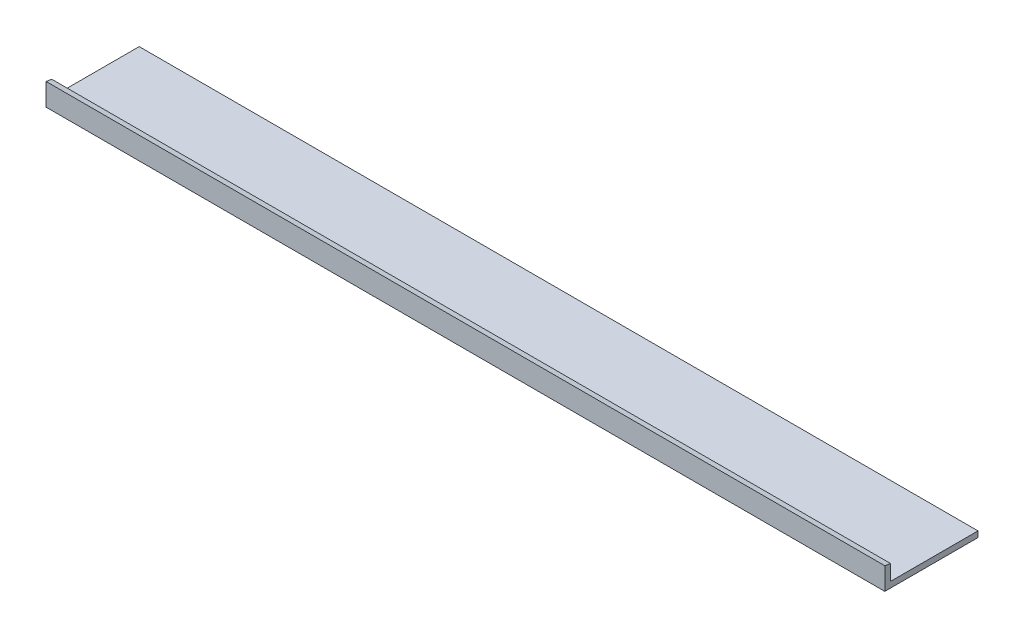
from build123d import *

# Parameters (mm, degrees)
SKETCH1_W           = 50.8
SKETCH1_H           = 12.13231
BOSS_EXTRUDE1_DEPTH = 457.2
CUT_EXTRUDE1_DEPTH  = 457.2


with BuildPart() as part:
    # Sketch1 → Boss-Extrude1 (new body)
    with BuildSketch(Plane(origin=(0, 0, 0), x_dir=(0, 0, -1), z_dir=(1, 0, 0))):
        with Locations((25.4, 6.066155)):
            Rectangle(SKETCH1_W, SKETCH1_H)
    extrude(amount=BOSS_EXTRUDE1_DEPTH)

    # Sketch2 → Cut-Extrude1 (cut)
    with BuildSketch(Plane.ZY):
        Polygon((-41.275, 12.13231), (-3.175, 12.13231), (0, 12.13231), (-3.175, 11.572471836), (-3.175, 3.175), (-41.275, 3.175), (-50.8, 3.175), (-50.8, 12.13231), align=None)
    extrude(amount=-CUT_EXTRUDE1_DEPTH, mode=Mode.SUBTRACT)


solid = part.part
